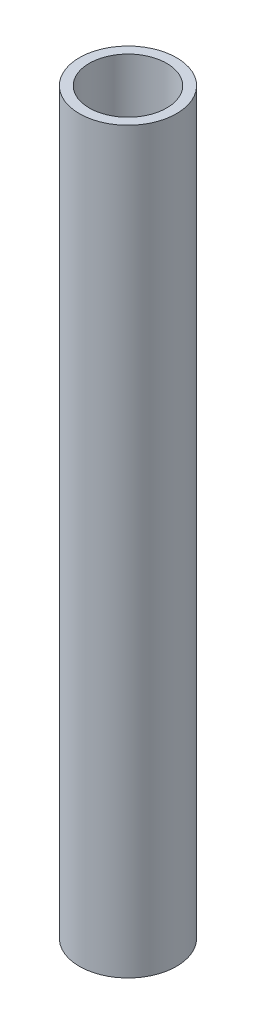
from build123d import *

# Parameters (mm, degrees)
SKETCH1_R           = 16.7005
SKETCH1_R_2         = 13.3223
BOSS_EXTRUDE1_DEPTH = 254


with BuildPart() as part:
    # Sketch1 → Boss-Extrude1 (new body)
    with BuildSketch(Plane(origin=(0, 0, 0), x_dir=(1, 0, 0), z_dir=(0, 1, 0))):
        Circle(SKETCH1_R)
        Circle(SKETCH1_R_2, mode=Mode.SUBTRACT)
    extrude(amount=BOSS_EXTRUDE1_DEPTH)


solid = part.part
